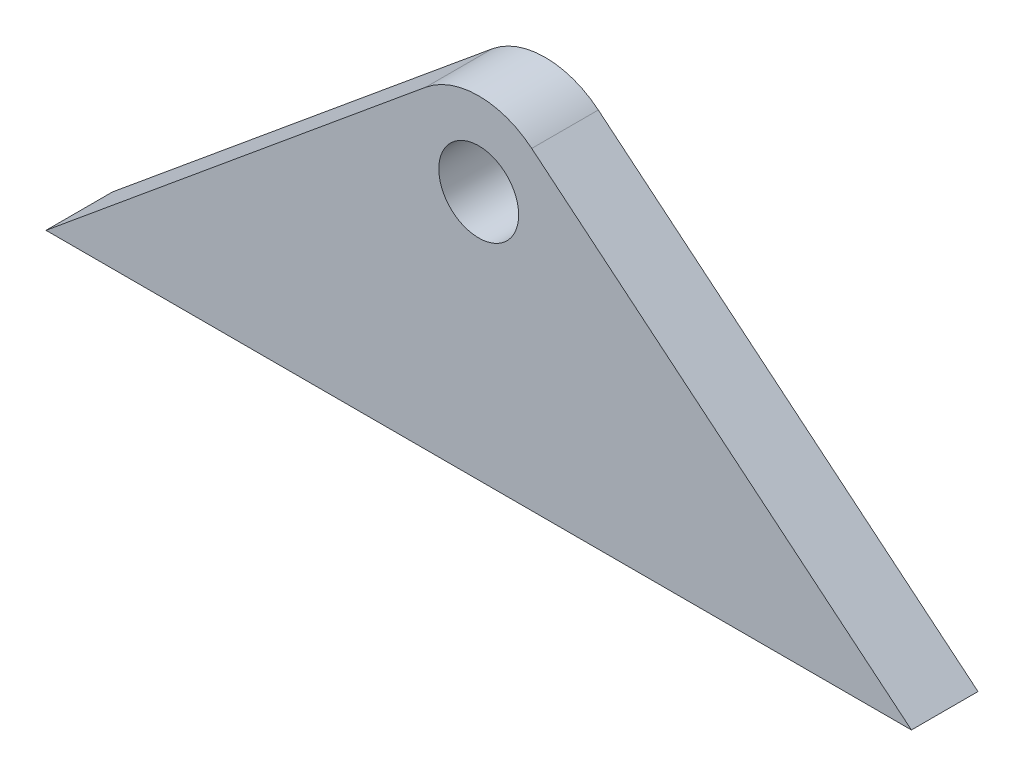
from build123d import *

# Parameters (mm, degrees)
CROQUIS1_R              = 12
SALIENTE_EXTRUIR1_DEPTH = 10


with BuildPart() as part:
    # Croquis1 → Saliente-Extruir1 (new body, symmetric)
    with BuildSketch(Plane.XY):
        with BuildLine():
            Line((130, 0), (-130, 0))
            Line((-130, 0), (-15.92562313, 94.271080092))
            ThreePointArc((-15.92562313, 94.271080092), (0, 100), (15.92562313, 94.271080092))
            Line((15.92562313, 94.271080092), (130, 0))
        make_face()
        with Locations((0, 75)):
            Circle(CROQUIS1_R, mode=Mode.SUBTRACT)
    extrude(amount=SALIENTE_EXTRUIR1_DEPTH, both=True)


solid = part.part
